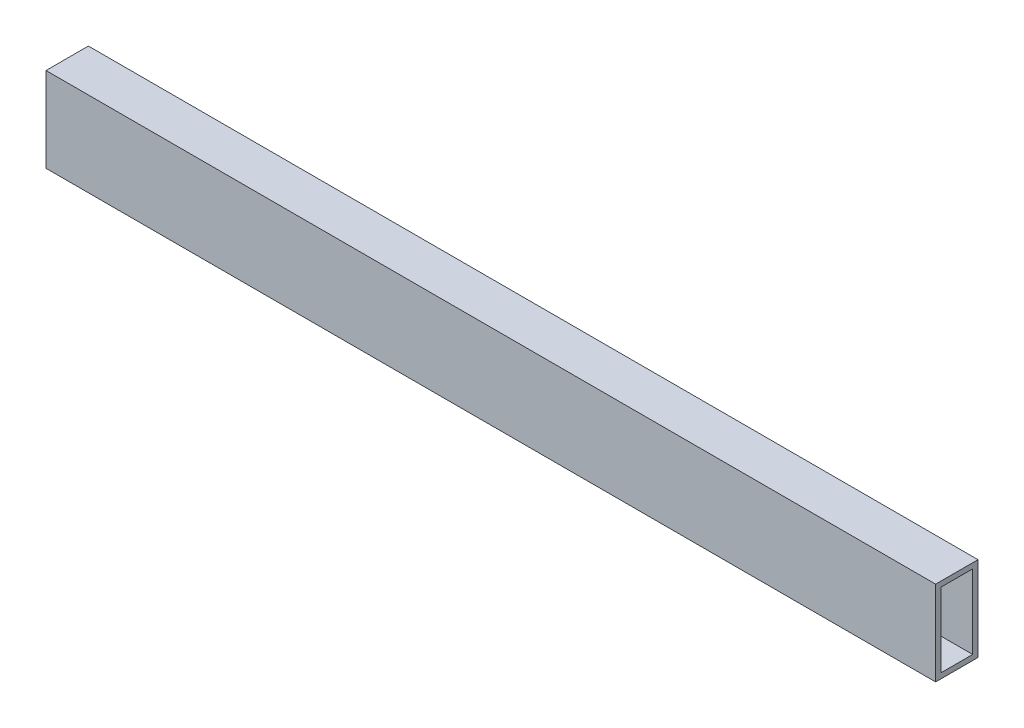
from build123d import *

# Parameters (mm, degrees)
SKETCH1_W           = 25.4
SKETCH1_H           = 50.8
SKETCH1_W_2         = 19.05
SKETCH1_H_2         = 44.45
BOSS_EXTRUDE1_DEPTH = 533.4


with BuildPart() as part:
    # Sketch1 → Boss-Extrude1 (new body)
    with BuildSketch(Plane(origin=(0, 0, 0), x_dir=(0, 0, -1), z_dir=(1, 0, 0))):
        with Locations((12.7, 25.4)):
            Rectangle(SKETCH1_W, SKETCH1_H)
        with Locations((12.7, 25.4)):
            Rectangle(SKETCH1_W_2, SKETCH1_H_2, mode=Mode.SUBTRACT)
    extrude(amount=BOSS_EXTRUDE1_DEPTH)


solid = part.part
